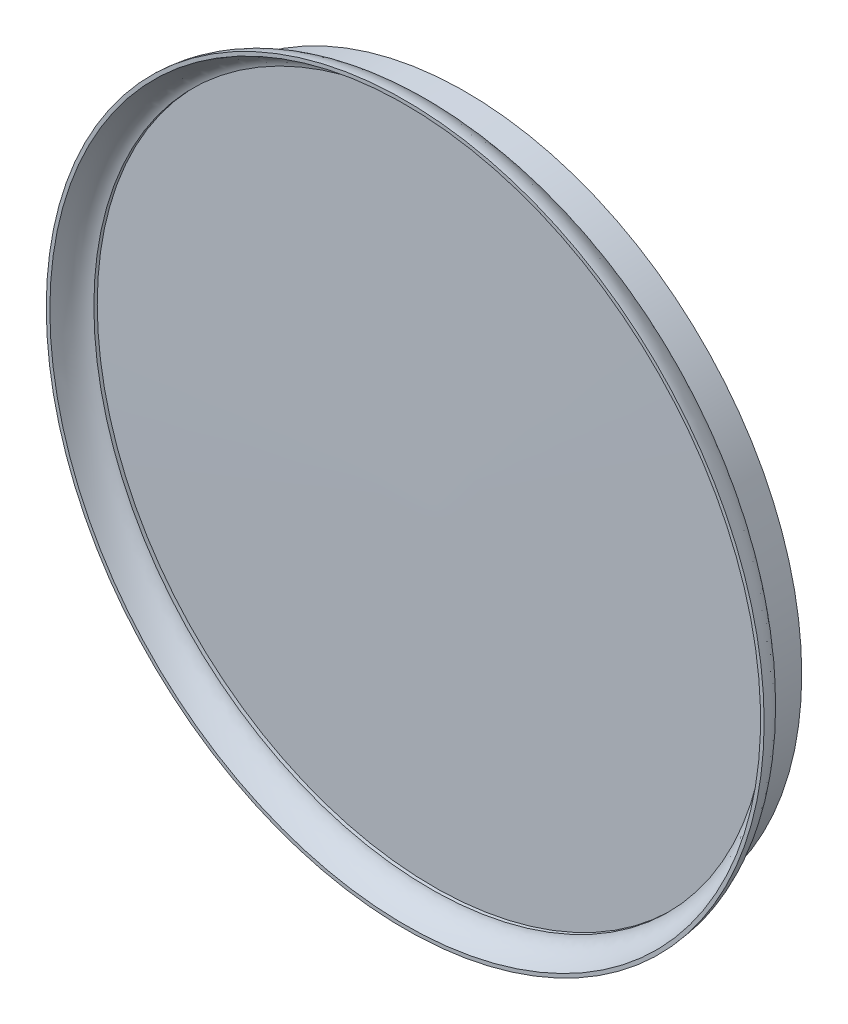
from build123d import *

# Parameters (mm, degrees)
SKETCH1_R           = 44.75
BOSS_EXTRUDE1_DEPTH = 4
SKETCH2_R           = 47.75
BOSS_EXTRUDE2_DEPTH = 4


with BuildPart() as part:
    # Sketch1 → Boss-Extrude1 (new body)
    with BuildSketch(Plane.XY):
        Circle(SKETCH1_R)
    extrude(amount=BOSS_EXTRUDE1_DEPTH)

    # Sketch2 → Boss-Extrude2 (add)
    with BuildSketch(Plane.XY.offset(4)):
        Circle(SKETCH2_R)
    extrude(amount=BOSS_EXTRUDE2_DEPTH)

    # Sketch3 → Cut-Revolve1 (revolve, cut)
    with BuildSketch(Plane(origin=(0, 0, 0), x_dir=(0, 0, -1), z_dir=(1, 0, 0))):
        with BuildLine():
            Line((-4, 47.75), (-4, 44.75))
            add(Edge.make_bspline(
                [(-4, 44.75), (-5.51655106, 47.70034682), (-8, 47.75)],
                knots=[0, 0, 0, 0.96689788, 0.96689788, 0.96689788], degree=2))
            Line((-8, 47.75), (-4, 47.75))
        make_face()
    revolve(axis=Axis((0, 0, 14.618090142), (0, 0, -1)), mode=Mode.SUBTRACT)

    # Sketch4 → Cut-Revolve3 (revolve, cut)
    with BuildSketch(Plane(origin=(0, 0, 0), x_dir=(0, 0, -1), z_dir=(1, 0, 0))):
        with BuildLine():
            Line((-4.667863656, 44.75), (-4.217612647, 44.75))
            Line((-4.217612647, 44.75), (-4.442738152, 0))
            Line((-4.442738152, 0), (-8, 0))
            Line((-8, 0), (-8, 47.272851402))
            add(Edge.make_bspline(
                [(-8, 47.272851402), (-5.020669257, 46.35865801), (-4.667863656, 44.75)],
                knots=[0, 0, 0, 0.52721511, 0.52721511, 0.52721511], degree=2))
        make_face()
    revolve(axis=Axis((0, 0, 4.442738152), (0, 0, 1)), mode=Mode.SUBTRACT)


solid = part.part
